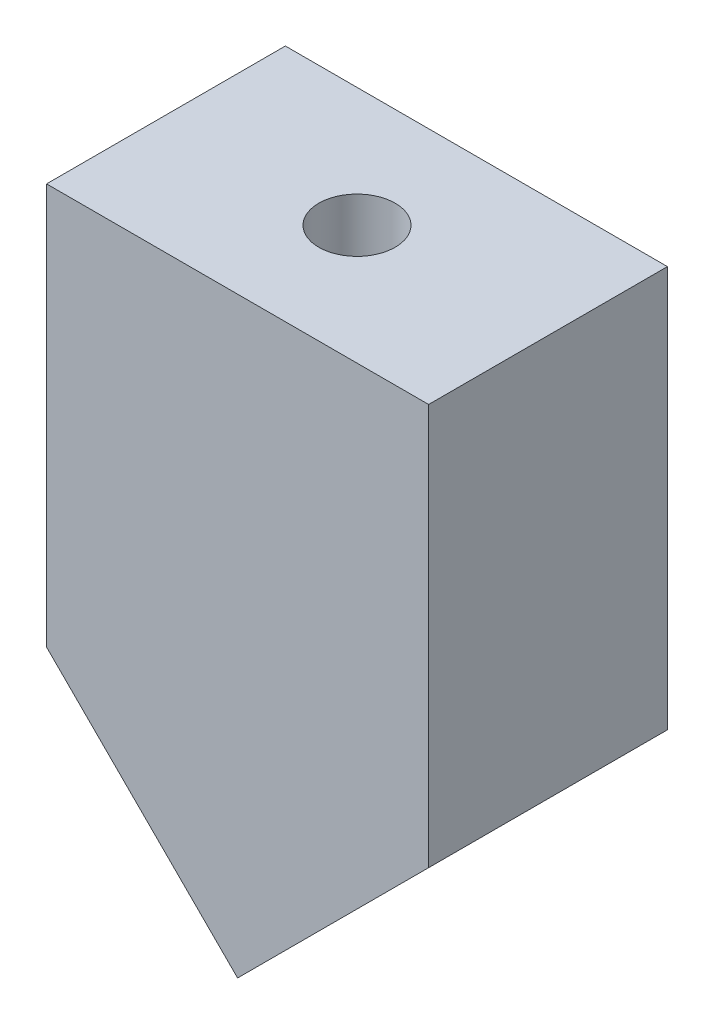
from build123d import *

# Parameters (mm, degrees)
SKETCH1_W           = 40
SKETCH1_H           = 62
BOSS_EXTRUDE1_DEPTH = 25
CUT_EXTRUDE1_DEPTH  = 25
SKETCH3_R           = 4
CUT_EXTRUDE2_DEPTH  = 30


with BuildPart() as part:
    # Sketch1 → Boss-Extrude1 (new body)
    with BuildSketch(Plane.XY):
        Rectangle(SKETCH1_W, SKETCH1_H)
    extrude(amount=BOSS_EXTRUDE1_DEPTH)

    # Sketch2 → Cut-Extrude1 (cut)
    with BuildSketch(Plane.XY.offset(25)):
        Polygon((0, -31), (-20, -11), (-20, -38.533016332), (20, -38.533016332), (20, -11), align=None)
    extrude(amount=-CUT_EXTRUDE1_DEPTH, mode=Mode.SUBTRACT)

    # Sketch3 → Cut-Extrude2 (cut)
    with BuildSketch(Plane(origin=(0, 31, 0), x_dir=(1, 0, 0), z_dir=(0, 1, 0))):
        with Locations((0, -12.5)):
            Circle(SKETCH3_R)
    extrude(amount=-CUT_EXTRUDE2_DEPTH, mode=Mode.SUBTRACT)


solid = part.part
